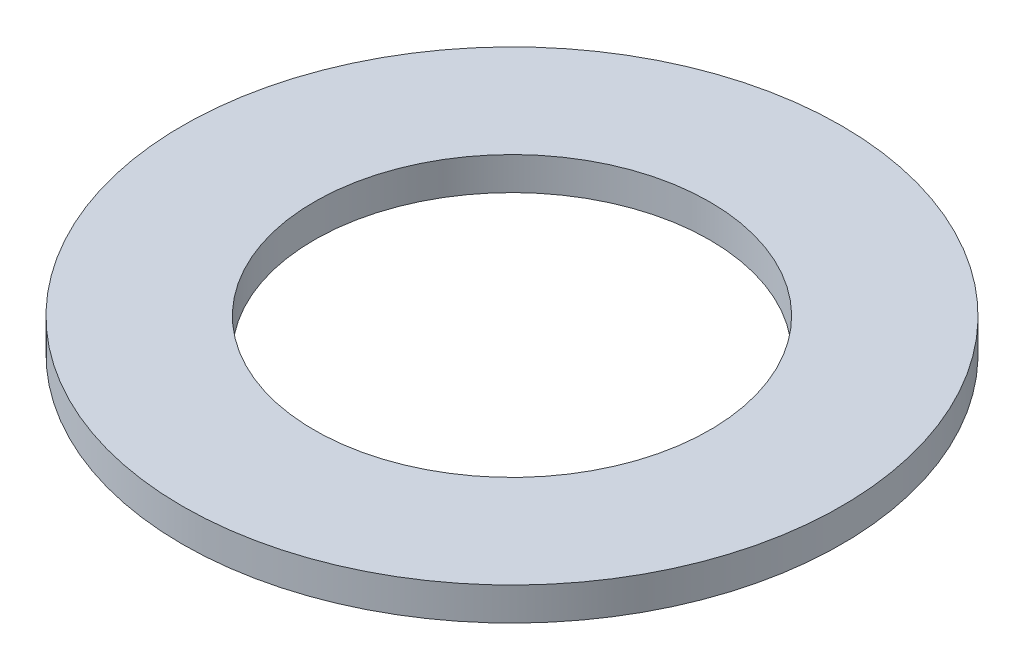
from build123d import *

# Parameters (mm, degrees)
SKETCH1_W = 1.5875
SKETCH1_H = 0.396875


with BuildPart() as part:
    # Sketch1 → Revolve1 (revolve)
    with BuildSketch(Plane.XY):
        with Locations((-3.175, 0.1984375)):
            Rectangle(SKETCH1_W, SKETCH1_H)
    revolve(axis=Axis((0, 0, 0), (0, 1, 0)))


solid = part.part
